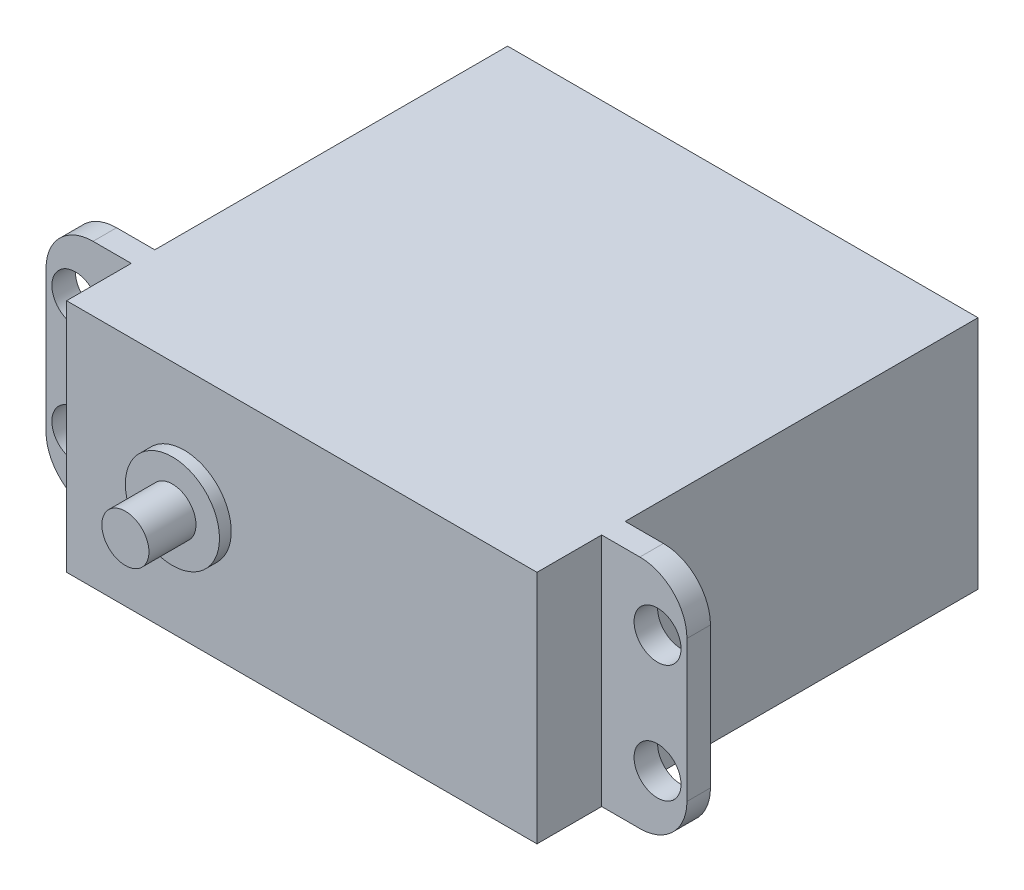
from build123d import *

# Parameters (mm, degrees)
SKETCH1_W           = 40
SKETCH1_H           = 20
BOSS_EXTRUDE2_DEPTH = 37.5
SKETCH2_W           = 2
SKETCH2_H           = 20
BOSS_EXTRUDE3_DEPTH = 7.25
SKETCH3_R           = 1.995473195
CUT_EXTRUDE1_DEPTH  = 2
FILLET3_R           = 4
SKETCH4_W           = 2
SKETCH4_H           = 20
BOSS_EXTRUDE4_DEPTH = 7.25
SKETCH5_R           = 2
CUT_EXTRUDE2_DEPTH  = 2
FILLET4_R           = 4
SKETCH6_R           = 4.001263217
BOSS_EXTRUDE5_DEPTH = 1
SKETCH7_R           = 2.001461963
BOSS_EXTRUDE7_DEPTH = 4


with BuildPart() as part:
    # Sketch1 → Boss-Extrude2 (new body)
    with BuildSketch(Plane.XY):
        Rectangle(SKETCH1_W, SKETCH1_H)
    extrude(amount=BOSS_EXTRUDE2_DEPTH)

    # Sketch2 → Boss-Extrude3 (add)
    with BuildSketch(Plane(origin=(20, 0, 0), x_dir=(0, 0, -1), z_dir=(1, 0, 0))):
        with Locations((-31, 0)):
            Rectangle(SKETCH2_W, SKETCH2_H)
    extrude(amount=BOSS_EXTRUDE3_DEPTH)

    # Sketch3 → Cut-Extrude1 (cut)
    with BuildSketch(Plane.XY.offset(32)):
        with Locations((24.75, -4.99913934)):
            Circle(SKETCH3_R)
        with Locations((24.75, 4.999429987)):
            Circle(SKETCH3_R)
    extrude(amount=-CUT_EXTRUDE1_DEPTH, mode=Mode.SUBTRACT)

    # Fillet3
    fillet3_edges = [part.edges().sort_by_distance(p)[0] for p in [
        (27.25, -10, 31),
        (27.25, 10, 31),
    ]]
    fillet(fillet3_edges, radius=FILLET3_R)

    # Sketch4 → Boss-Extrude4 (add)
    with BuildSketch(Plane.ZY.offset(20)):
        with Locations((31, 0)):
            Rectangle(SKETCH4_W, SKETCH4_H)
    extrude(amount=BOSS_EXTRUDE4_DEPTH)

    # Sketch5 → Cut-Extrude2 (cut)
    with BuildSketch(Plane.XY.offset(32)):
        with Locations((-24.75, 5)):
            Circle(SKETCH5_R)
        with Locations((-24.75, -5)):
            Circle(SKETCH5_R)
    extrude(amount=-CUT_EXTRUDE2_DEPTH, mode=Mode.SUBTRACT)

    # Fillet4
    fillet4_edges = [part.edges().sort_by_distance(p)[0] for p in [
        (-27.25, -10, 31),
        (-27.25, 10, 31),
    ]]
    fillet(fillet4_edges, radius=FILLET4_R)

    # Sketch6 → Boss-Extrude5 (add)
    with BuildSketch(Plane.XY.offset(37.5)):
        with Locations((-10, 0)):
            Circle(SKETCH6_R)
    extrude(amount=BOSS_EXTRUDE5_DEPTH)

    # Sketch7 → Boss-Extrude7 (add)
    with BuildSketch(Plane.XY.offset(38.5)):
        with Locations((-10, 0)):
            Circle(SKETCH7_R)
    extrude(amount=BOSS_EXTRUDE7_DEPTH)


solid = part.part
